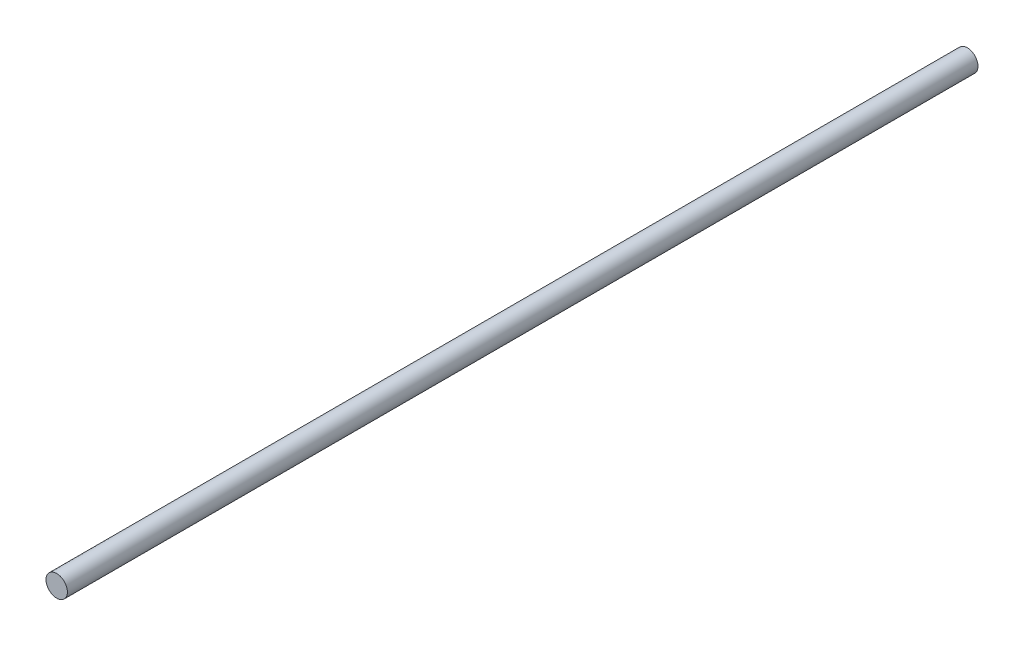
from build123d import *

# Parameters (mm, degrees)
SKETCH1_R           = 4
BOSS_EXTRUDE1_DEPTH = 340


with BuildPart() as part:
    # Sketch1 → Boss-Extrude1 (new body)
    with BuildSketch(Plane.XY):
        Circle(SKETCH1_R)
    extrude(amount=BOSS_EXTRUDE1_DEPTH)


solid = part.part
